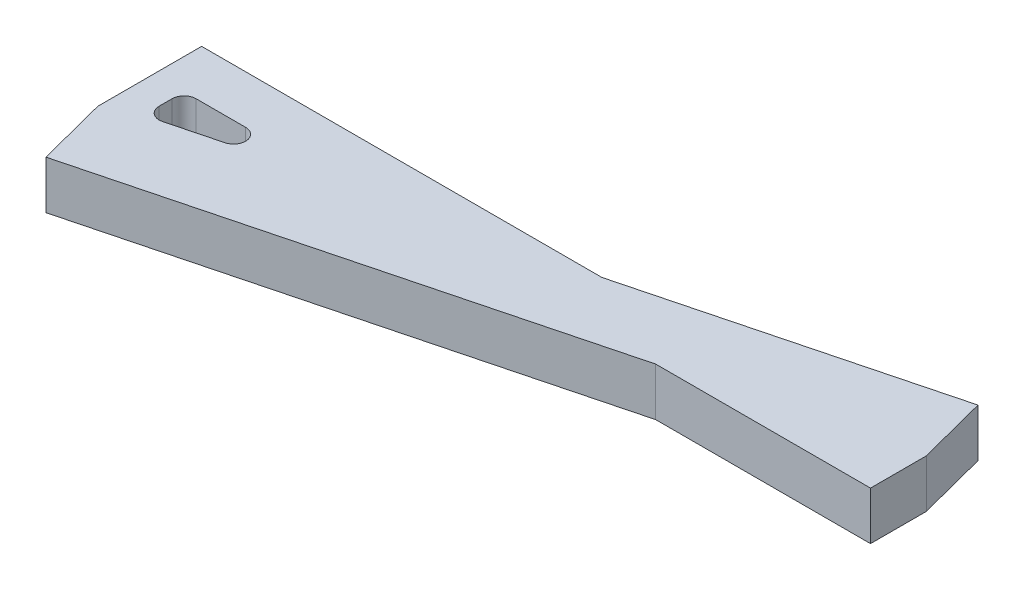
from build123d import *

# Parameters (mm, degrees)
BOSS_EXTRUDE1_DEPTH = 2


with BuildPart() as part:
    # Sketch1 → Boss-Extrude1 (new body)
    with BuildSketch(Plane(origin=(0, 0, 0), x_dir=(1, 0, 0), z_dir=(0, 1, 0))):
        Polygon((0, 0), (20.112843107, 5.220264813), (29.03786322, 5.220264813), (29.03786322, 7.220264813), (29.03786322, 7.536743304), (28.284188889, 10.440529626), (15.877025026, 7.220264813), (-0.75367433, 7.220264813), (-0.75367433, 5.220264813), (-0.75367433, 2.903786322), align=None)
        with BuildLine():
            Line((0.516929559, 4.720264813), (0.516929559, 4.186250024))
            ThreePointArc((0.516929559, 4.186250024), (0.71099345, 3.79077171), (1.142541948, 3.702285637))
            Line((1.142541948, 3.702285637), (3.200015285, 4.236300426))
            ThreePointArc((3.200015285, 4.236300426), (3.570377792, 4.783580714), (3.074402897, 5.220264813))
            Line((3.074402897, 5.220264813), (1.016929559, 5.220264813))
            ThreePointArc((1.016929559, 5.220264813), (0.663376169, 5.073818204), (0.516929559, 4.720264813))
        make_face(mode=Mode.SUBTRACT)
    extrude(amount=BOSS_EXTRUDE1_DEPTH)


solid = part.part
